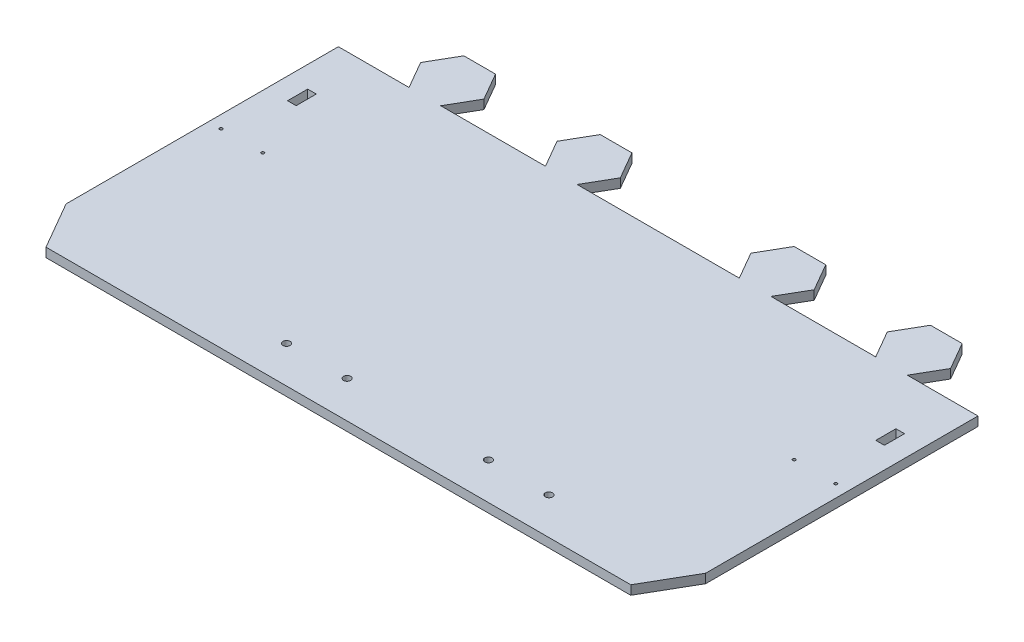
from build123d import *

# Parameters (mm, degrees)
SKETCH1_W           = 444.5
SKETCH1_H           = 222.25
BOSS_EXTRUDE1_DEPTH = 6.35
BOSS_EXTRUDE2_DEPTH = 6.35
CUT_EXTRUDE1_DEPTH  = 7.35
SKETCH5_R           = 2.5
CUT_EXTRUDE2_DEPTH  = 7.35
SKETCH6_R           = 1.016
CUT_EXTRUDE3_DEPTH  = 7.35
SKETCH7_W           = 5.969
SKETCH7_H           = 14
CUT_EXTRUDE4_DEPTH  = 7.35


with BuildPart() as part:
    # Sketch1 → Boss-Extrude1 (new body)
    with BuildSketch(Plane(origin=(0, 0, 0), x_dir=(1, 0, 0), z_dir=(0, 1, 0))):
        with Locations((222.25, 111.125)):
            Rectangle(SKETCH1_W, SKETCH1_H)
    extrude(amount=BOSS_EXTRUDE1_DEPTH)

    # Sketch3 → Boss-Extrude2 (add)
    with BuildSketch(Plane(origin=(0, 6.35, 0), x_dir=(1, 0, 0), z_dir=(0, 1, 0))):
        Polygon((82.094090512, 241.3), (71.095567884, 260.35), (49.098522628, 260.35), (38.1, 241.3), (49.098522628, 222.25), (71.095567884, 222.25), align=None)
        Polygon((143.89261314, 222.25), (132.894090512, 241.3), (143.89261314, 260.35), (165.889658396, 260.35), (176.888181024, 241.3), (165.889658396, 222.25), align=None)
        Polygon((311.605909488, 241.3), (300.60738686, 260.35), (278.610341604, 260.35), (267.611818976, 241.3), (278.610341604, 222.25), (300.60738686, 222.25), align=None)
        Polygon((373.404432116, 222.25), (362.405909488, 241.3), (373.404432116, 260.35), (395.401477372, 260.35), (406.4, 241.3), (395.401477372, 222.25), align=None)
    extrude(amount=-BOSS_EXTRUDE2_DEPTH)

    # Sketch4 → Cut-Extrude1 (cut, through all)
    with BuildSketch(Plane(origin=(0, 6.35, 0), x_dir=(1, 0, 0), z_dir=(0, 1, 0))):
        Polygon((0, 0), (0, 32.995567884), (19.05, 0), align=None)
        Polygon((444.5, 0), (444.5, 32.995567884), (425.45, 0), align=None)
    extrude(amount=-CUT_EXTRUDE1_DEPTH, mode=Mode.SUBTRACT)

    # Sketch5 → Cut-Extrude2 (cut, through all)
    with BuildSketch(Plane(origin=(0, 6.35, 0), x_dir=(1, 0, 0), z_dir=(0, 1, 0))):
        with Locations((342.9, 25.65)):
            Circle(SKETCH5_R)
        with Locations((300.84, 25.65)):
            Circle(SKETCH5_R)
        with Locations((202.66, 25.65)):
            Circle(SKETCH5_R)
        with Locations((160.6, 25.65)):
            Circle(SKETCH5_R)
    extrude(amount=-CUT_EXTRUDE2_DEPTH, mode=Mode.SUBTRACT)

    # Sketch6 → Cut-Extrude3 (cut, through all)
    with BuildSketch(Plane(origin=(0, 6.35, 0), x_dir=(1, 0, 0), z_dir=(0, 1, 0))):
        with Locations((406.91200009, 132.065900124)):
            Circle(SKETCH6_R)
        with Locations((37.58799991, 132.065900124)):
            Circle(SKETCH6_R)
        with Locations((435.85200009, 132.065900124)):
            Circle(SKETCH6_R)
        with Locations((8.64799991, 132.065900124)):
            Circle(SKETCH6_R)
    extrude(amount=-CUT_EXTRUDE3_DEPTH, mode=Mode.SUBTRACT)

    # Sketch7 → Cut-Extrude4 (cut, through all)
    with BuildSketch(Plane(origin=(0, 6.35, 0), x_dir=(1, 0, 0), z_dir=(0, 1, 0))):
        with Locations((426.6565, 179.061000022)):
            Rectangle(SKETCH7_W, SKETCH7_H)
        with Locations((17.8435, 179.061000022)):
            Rectangle(SKETCH7_W, SKETCH7_H)
    extrude(amount=-CUT_EXTRUDE4_DEPTH, mode=Mode.SUBTRACT)


solid = part.part
